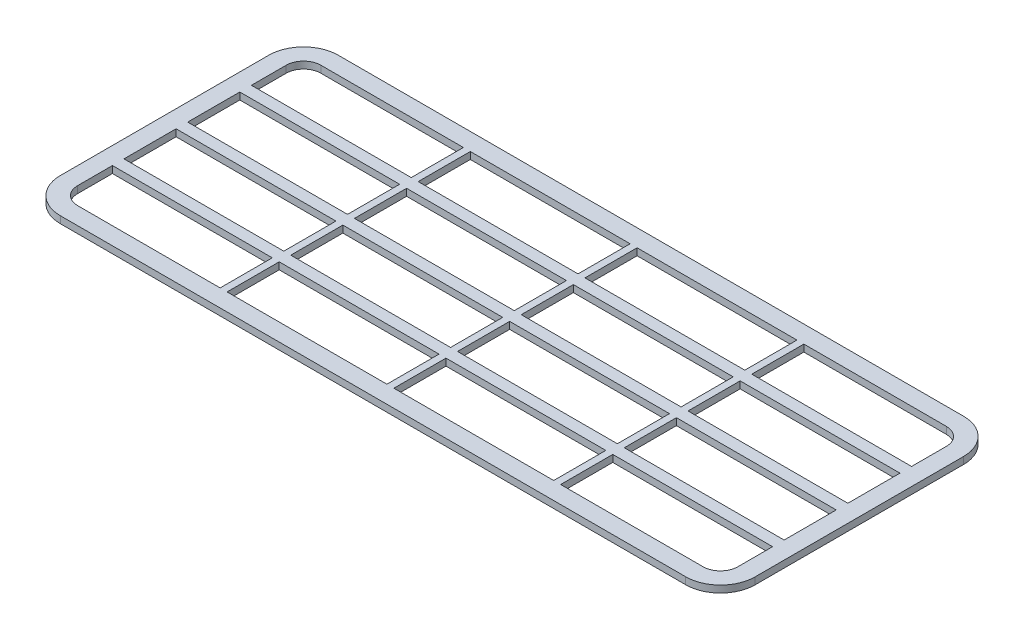
from build123d import *

# Parameters (mm, degrees)
SKETCH1_W           = 23
SKETCH1_H           = 7.5
BOSS_EXTRUDE1_DEPTH = 1


with BuildPart() as part:
    # Sketch1 → Boss-Extrude1 (new body)
    with BuildSketch(Plane(origin=(0, 0, 0), x_dir=(1, 0, 0), z_dir=(0, 1, 0))):
        with BuildLine():
            Line((-68.681780825, 26.812567087), (21.318219175, 26.812567087))
            ThreePointArc((21.318219175, 26.812567087), (24.853753081, 25.348100993), (26.318219175, 21.812567087))
            Line((26.318219175, 21.812567087), (26.318219175, -8.187432913))
            ThreePointArc((26.318219175, -8.187432913), (24.853753081, -11.722966819), (21.318219175, -13.187432913))
            Line((21.318219175, -13.187432913), (-68.681780825, -13.187432913))
            ThreePointArc((-68.681780825, -13.187432913), (-72.217314731, -11.722966819), (-73.681780825, -8.187432913))
            Line((-73.681780825, -8.187432913), (-73.681780825, 21.812567087))
            ThreePointArc((-73.681780825, 21.812567087), (-72.217314731, 25.348100993), (-68.681780825, 26.812567087))
        make_face()
        with BuildLine():
            Line((-71.181780825, 16.812567087), (-48.181780825, 16.812567087))
            Line((-48.181780825, 16.812567087), (-48.181780825, 24.312567087))
            Line((-48.181780825, 24.312567087), (-68.681780825, 24.312567087))
            ThreePointArc((-68.681780825, 24.312567087), (-70.449547778, 23.58033404), (-71.181780825, 21.812567087))
            Line((-71.181780825, 21.812567087), (-71.181780825, 16.812567087))
        make_face(mode=Mode.SUBTRACT)
        with Locations((12.318219175, 11.392567087)):
            Rectangle(SKETCH1_W, SKETCH1_H, mode=Mode.SUBTRACT)
        with BuildLine():
            Line((-71.181780825, -3.187432913), (-48.181780825, -3.187432913))
            Line((-48.181780825, -3.187432913), (-48.181780825, -10.687432913))
            Line((-48.181780825, -10.687432913), (-68.681780825, -10.687432913))
            ThreePointArc((-68.681780825, -10.687432913), (-70.449547778, -9.955199866), (-71.181780825, -8.187432913))
            Line((-71.181780825, -8.187432913), (-71.181780825, -3.187432913))
        make_face(mode=Mode.SUBTRACT)
        with Locations((-35.681780825, 20.562567087)):
            Rectangle(SKETCH1_W, SKETCH1_H, mode=Mode.SUBTRACT)
        with Locations((-11.681780825, 20.562567087)):
            Rectangle(SKETCH1_W, SKETCH1_H, mode=Mode.SUBTRACT)
        with BuildLine():
            Line((0.818219175, 24.312567087), (0.818219175, 16.812567087))
            Line((0.818219175, 16.812567087), (23.818219175, 16.812567087))
            Line((23.818219175, 16.812567087), (23.818219175, 21.812567087))
            ThreePointArc((23.818219175, 21.812567087), (23.085986128, 23.58033404), (21.318219175, 24.312567087))
            Line((21.318219175, 24.312567087), (0.818219175, 24.312567087))
        make_face(mode=Mode.SUBTRACT)
        with Locations((-35.681780825, -6.937432913)):
            Rectangle(SKETCH1_W, SKETCH1_H, mode=Mode.SUBTRACT)
        with Locations((-59.681780825, 11.392567087)):
            Rectangle(SKETCH1_W, SKETCH1_H, mode=Mode.SUBTRACT)
        with Locations((-35.681780825, 11.392567087)):
            Rectangle(SKETCH1_W, SKETCH1_H, mode=Mode.SUBTRACT)
        with Locations((-11.681780825, -6.937432913)):
            Rectangle(SKETCH1_W, SKETCH1_H, mode=Mode.SUBTRACT)
        with BuildLine():
            Line((0.818219175, -10.687432913), (21.318219175, -10.687432913))
            ThreePointArc((21.318219175, -10.687432913), (23.085986128, -9.955199866), (23.818219175, -8.187432913))
            Line((23.818219175, -8.187432913), (23.818219175, -3.187432913))
            Line((23.818219175, -3.187432913), (0.818219175, -3.187432913))
            Line((0.818219175, -3.187432913), (0.818219175, -10.687432913))
        make_face(mode=Mode.SUBTRACT)
        with Locations((-11.681780825, 11.392567087)):
            Rectangle(SKETCH1_W, SKETCH1_H, mode=Mode.SUBTRACT)
        with Locations((-59.681780825, 2.222567087)):
            Rectangle(SKETCH1_W, SKETCH1_H, mode=Mode.SUBTRACT)
        with Locations((-35.681780825, 2.222567087)):
            Rectangle(SKETCH1_W, SKETCH1_H, mode=Mode.SUBTRACT)
        with Locations((-11.681780825, 2.222567087)):
            Rectangle(SKETCH1_W, SKETCH1_H, mode=Mode.SUBTRACT)
        with Locations((12.318219175, 2.222567087)):
            Rectangle(SKETCH1_W, SKETCH1_H, mode=Mode.SUBTRACT)
    extrude(amount=BOSS_EXTRUDE1_DEPTH)


solid = part.part
